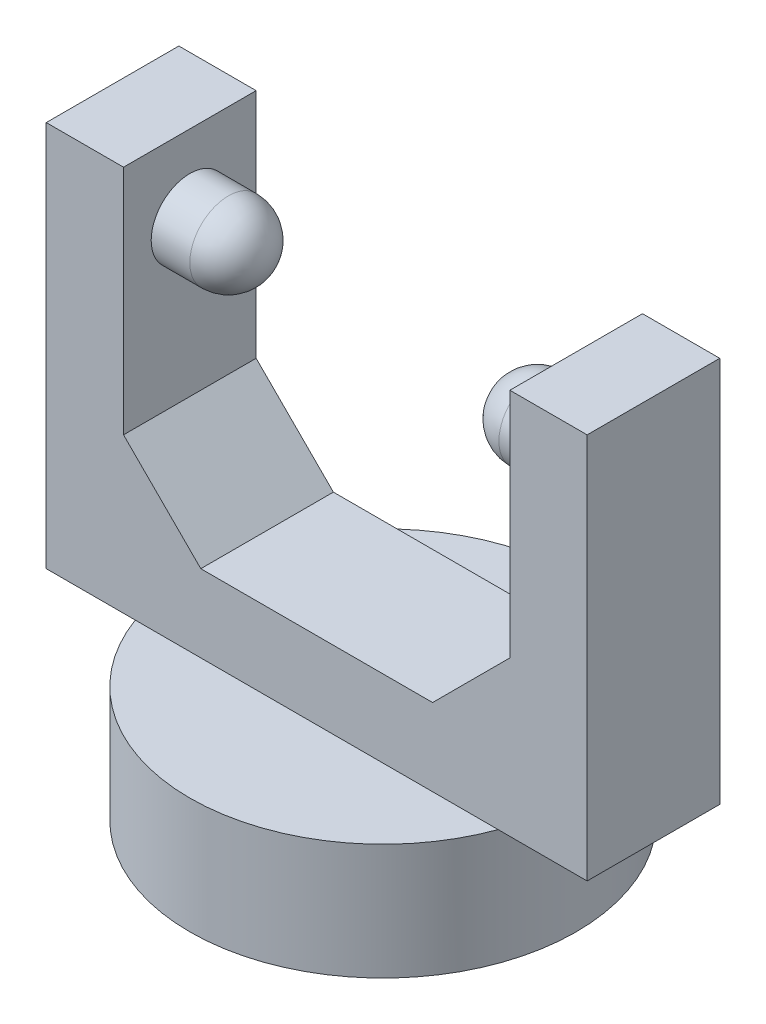
from build123d import *

# Parameters (mm, degrees)
SKETCH1_R           = 12.5
BOSS_EXTRUDE1_DEPTH = 7.5
SKETCH2_W           = 35
SKETCH2_H           = 8.580767914
BOSS_EXTRUDE2_DEPTH = 25
SKETCH3_W           = 25
SKETCH3_H           = 8.580767914
CUT_EXTRUDE1_DEPTH  = 20
SKETCH4_R           = 2.5
BOSS_EXTRUDE3_DEPTH = 5
SKETCH5_R           = 2.5
BOSS_EXTRUDE4_DEPTH = 5
CHAMFER1_SIZE       = 5
CHAMFER2_SIZE       = 5
FILLET1_R           = 2.5
FILLET2_R           = 2.5


with BuildPart() as part:
    # Sketch1 → Boss-Extrude1 (new body)
    with BuildSketch(Plane(origin=(0, 0, 0), x_dir=(1, 0, 0), z_dir=(0, 1, 0))):
        Circle(SKETCH1_R)
    extrude(amount=BOSS_EXTRUDE1_DEPTH)

    # Sketch2 → Boss-Extrude2 (add)
    with BuildSketch(Plane(origin=(0, 7.5, 0), x_dir=(1, 0, 0), z_dir=(0, 1, 0))):
        Rectangle(SKETCH2_W, SKETCH2_H)
    extrude(amount=BOSS_EXTRUDE2_DEPTH)

    # Sketch3 → Cut-Extrude1 (cut)
    with BuildSketch(Plane(origin=(0, 32.5, 0), x_dir=(1, 0, 0), z_dir=(0, 1, 0))):
        Rectangle(SKETCH3_W, SKETCH3_H)
    extrude(amount=-CUT_EXTRUDE1_DEPTH, mode=Mode.SUBTRACT)

    # Sketch4 → Boss-Extrude3 (add)
    with BuildSketch(Plane(origin=(-12.5, 0, 0), x_dir=(0, 0, -1), z_dir=(1, 0, 0))):
        with Locations((0, 27.5)):
            Circle(SKETCH4_R)
    extrude(amount=BOSS_EXTRUDE3_DEPTH)

    # Sketch5 → Boss-Extrude4 (add)
    with BuildSketch(Plane.ZY.offset(-12.5)):
        with Locations((0, 27.5)):
            Circle(SKETCH5_R)
    extrude(amount=BOSS_EXTRUDE4_DEPTH)

    # Chamfer1
    chamfer1_edges = [part.edges().sort_by_distance(p)[0] for p in [
        (-12.5, 12.5, 0),
    ]]
    chamfer(chamfer1_edges, length=CHAMFER1_SIZE)

    # Chamfer2
    chamfer2_edges = [part.edges().sort_by_distance(p)[0] for p in [
        (12.5, 12.5, 0),
    ]]
    chamfer(chamfer2_edges, length=CHAMFER2_SIZE)

    # Fillet1
    fillet1_edges = [part.edges().sort_by_distance(p)[0] for p in [
        (-7.5, 27.5, 2.5),
    ]]
    fillet(fillet1_edges, radius=FILLET1_R)

    # Fillet2
    fillet2_edges = [part.edges().sort_by_distance(p)[0] for p in [
        (7.5, 27.5, -2.5),
    ]]
    fillet(fillet2_edges, radius=FILLET2_R)


solid = part.part
